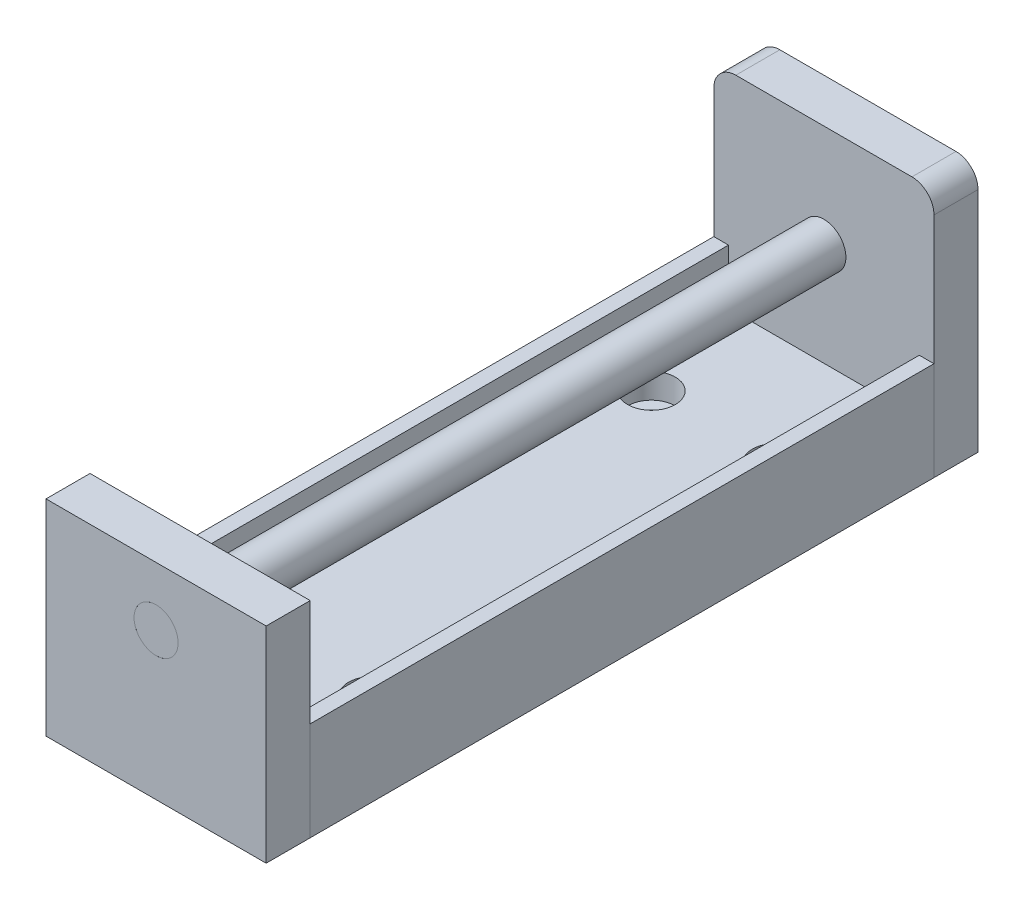
from build123d import *

# Parameters (mm, degrees)
SKETCH1_W                                    = 30
SKETCH1_H                                    = 34
BOSS_EXTRUDE1_DEPTH                          = 6
BOSS_EXTRUDE2_DEPTH                          = 85
SKETCH3_W                                    = 30
SKETCH3_H                                    = 28
BOSS_EXTRUDE3_DEPTH                          = 6
FILLET1_R                                    = 3
SKETCH4_R                                    = 3
CUT_EXTRUDE1_DEPTH                           = 92
CUT_EXTRUDE1_DEPTH_BACK                      = 7
BOSS_EXTRUDE4_START                          = -6
SKETCH4_2_R                                  = 3
BOSS_EXTRUDE4_DEPTH                          = 97
CBORE_FOR_M3_HEX_SOCKET_HEAD_CAP_SCR_2_COUNT = 2
CBORE_FOR_M3_HEX_SOCKET_HEAD_CAP_SCR_2_PITCH = 17
CBORE_FOR_M3_HEX_SOCKET_HEAD_CAP_SCR_3_COUNT = 2
CBORE_FOR_M3_HEX_SOCKET_HEAD_CAP_SCR_3_PITCH = 57.567351858
CBORE_FOR_M3_HEX_SOCKET_HEAD_CAP_SCR_4_COUNT = 2
CBORE_FOR_M3_HEX_SOCKET_HEAD_CAP_SCR_4_PITCH = 55


with BuildPart() as part:
    # Sketch1 → Boss-Extrude1 (new body)
    with BuildSketch(Plane.XY.offset(15)):
        with Locations((0, -3)):
            Rectangle(SKETCH1_W, SKETCH1_H)
    extrude(amount=BOSS_EXTRUDE1_DEPTH)

    # Fillet1
    fillet1_edges = [part.edges().sort_by_distance(p)[0] for p in [
        (-15, 14, 18),
        (15, 14, 18),
    ]]
    fillet(fillet1_edges, radius=FILLET1_R)


with BuildPart() as body_2:
    # Sketch2 → Boss-Extrude2 (new body)
    with BuildSketch(Plane.XY.offset(21)):
        Polygon((-15, -6.55), (-13, -6.55), (-13, -14), (13, -14), (13, -6.55), (15, -6.55), (15, -20), (-15, -20), align=None)
    extrude(amount=BOSS_EXTRUDE2_DEPTH)

    # Sketch7 → CBORE for M3 Hex Socket Head Cap Screw1 (revolve, cut)
    with BuildSketch(Plane(origin=(-8.5, -14, 36), x_dir=(0, 0, 1), z_dir=(1, 0, 0))):
        Polygon((0, 0), (0, 6), (1.6, 6), (1.6, 3.4), (3.25, 3.4), (3.25, 0), align=None)
    cbore_for_m3_hex_socket_head_cap_screw1 = revolve(axis=Axis((-8.5, -7.65, 36), (0, -1, 0)), mode=Mode.SUBTRACT)

    # CBORE for M3 Hex Socket Head Cap Scr 2: CBORE for M3 Hex Socket Head Cap Screw1 ×2
    with Locations(*[(i * CBORE_FOR_M3_HEX_SOCKET_HEAD_CAP_SCR_2_PITCH, 0, 0) for i in range(1, CBORE_FOR_M3_HEX_SOCKET_HEAD_CAP_SCR_2_COUNT)]):
        add(cbore_for_m3_hex_socket_head_cap_screw1, mode=Mode.SUBTRACT)

    # CBORE for M3 Hex Socket Head Cap Scr 3: CBORE for M3 Hex Socket Head Cap Screw1 ×2
    with Locations(*[Vector(0.295306271, 0, 0.955402641) * (i * CBORE_FOR_M3_HEX_SOCKET_HEAD_CAP_SCR_3_PITCH) for i in range(1, CBORE_FOR_M3_HEX_SOCKET_HEAD_CAP_SCR_3_COUNT)]):
        add(cbore_for_m3_hex_socket_head_cap_screw1, mode=Mode.SUBTRACT)

    # CBORE for M3 Hex Socket Head Cap Scr 4: CBORE for M3 Hex Socket Head Cap Screw1 ×2
    with Locations(*[(0, 0, i * CBORE_FOR_M3_HEX_SOCKET_HEAD_CAP_SCR_4_PITCH) for i in range(1, CBORE_FOR_M3_HEX_SOCKET_HEAD_CAP_SCR_4_COUNT)]):
        add(cbore_for_m3_hex_socket_head_cap_screw1, mode=Mode.SUBTRACT)


with BuildPart() as body_3:
    # Sketch3 → Boss-Extrude3 (new body)
    with BuildSketch(Plane.XY.offset(106)):
        with Locations((0, -6)):
            Rectangle(SKETCH3_W, SKETCH3_H)
    extrude(amount=BOSS_EXTRUDE3_DEPTH)


with BuildPart() as cut_extrude1_tool:
    # Sketch4 → Cut-Extrude1 (new body, two sides)
    with BuildSketch(Plane.XY.offset(21)) as cut_extrude1_sk:
        Circle(SKETCH4_R)
    extrude(amount=CUT_EXTRUDE1_DEPTH)
    extrude(cut_extrude1_sk.sketch, amount=-CUT_EXTRUDE1_DEPTH_BACK)


with BuildPart() as part_1:
    add(part.part)

    # Cut-Extrude1: cut by cut_extrude1_tool
    add(cut_extrude1_tool.part, mode=Mode.SUBTRACT)


with BuildPart() as body_3_1:
    add(body_3.part)

    # Cut-Extrude1: cut by cut_extrude1_tool
    add(cut_extrude1_tool.part, mode=Mode.SUBTRACT)


with BuildPart() as body_4:
    # Sketch4_2 → Boss-Extrude4 (new body)
    with BuildSketch(Plane.XY.offset(21).offset(BOSS_EXTRUDE4_START)):
        Circle(SKETCH4_2_R)
    extrude(amount=BOSS_EXTRUDE4_DEPTH)


solid = Compound([body_2.part, part_1.part, body_3_1.part, body_4.part])
